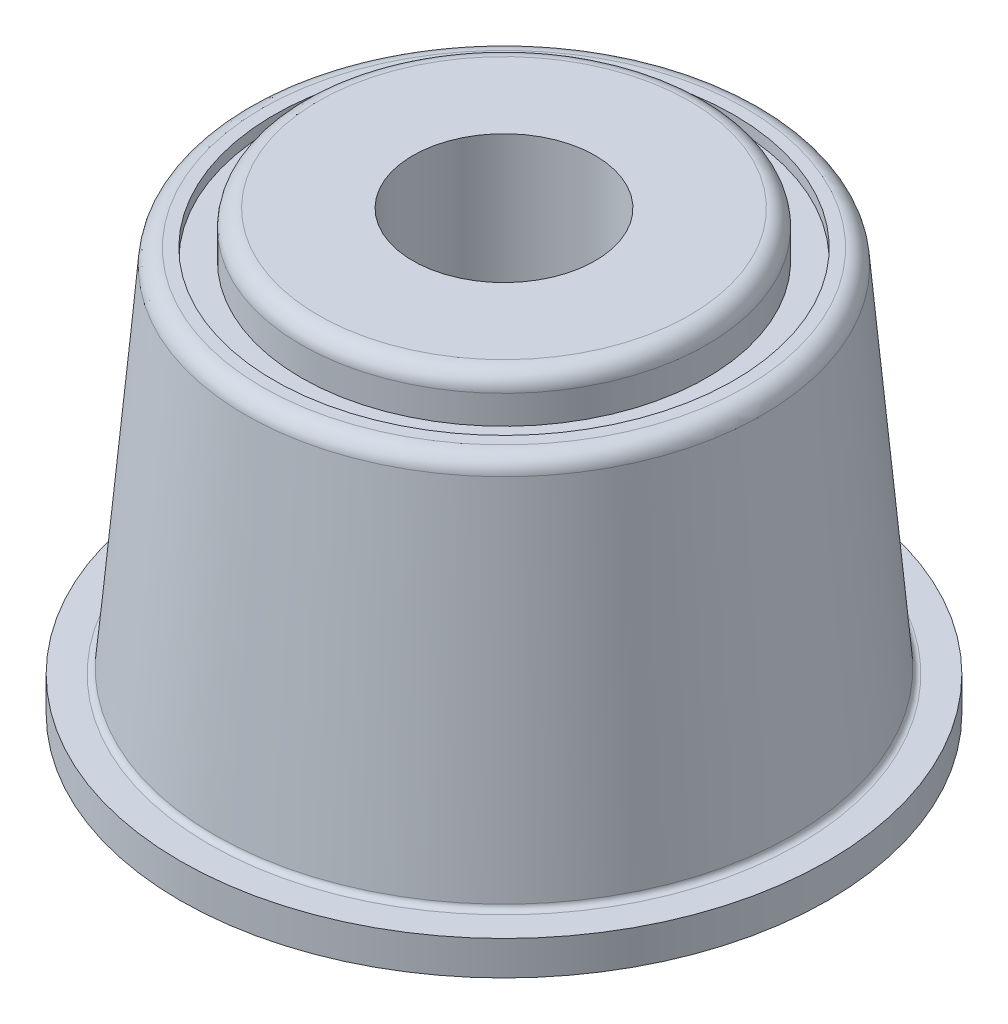
from build123d import *


with BuildPart() as part:
    # Sketch1 → Revolve1 (revolve)
    with BuildSketch(Plane.XY):
        with BuildLine():
            Line((4.07, 9.6), (2, 9.6))
            Line((2, 9.6), (2, -0.75))
            Line((2, -0.75), (4.445, -0.75))
            Line((4.445, -0.75), (4.445, -0.125))
            ThreePointArc((4.445, -0.125), (4.481611652, -0.036611652), (4.57, 0))
            Line((4.57, 0), (7.1, 0))
            Line((7.1, 0), (7.1, 0.75))
            Line((7.1, 0.75), (6.464541397, 0.75))
            ThreePointArc((6.464541397, 0.75), (6.380092621, 0.782840333), (6.340017059, 0.864105532))
            Line((6.340017059, 0.864105532), (5.671290647, 8.507683404))
            ThreePointArc((5.671290647, 8.507683404), (5.551063963, 8.751479001), (5.297717635, 8.85))
            Line((5.297717635, 8.85), (5.043170913, 8.85))
            Line((5.043170913, 8.85), (5.043170913, 8.6))
            Line((5.043170913, 8.6), (4.445, 8.6))
            Line((4.445, 8.6), (4.445, 9.225))
            ThreePointArc((4.445, 9.225), (4.335165043, 9.490165043), (4.07, 9.6))
        make_face()
    revolve(axis=Axis((0, 9.60267581, 0), (0, -1, 0)))


solid = part.part
